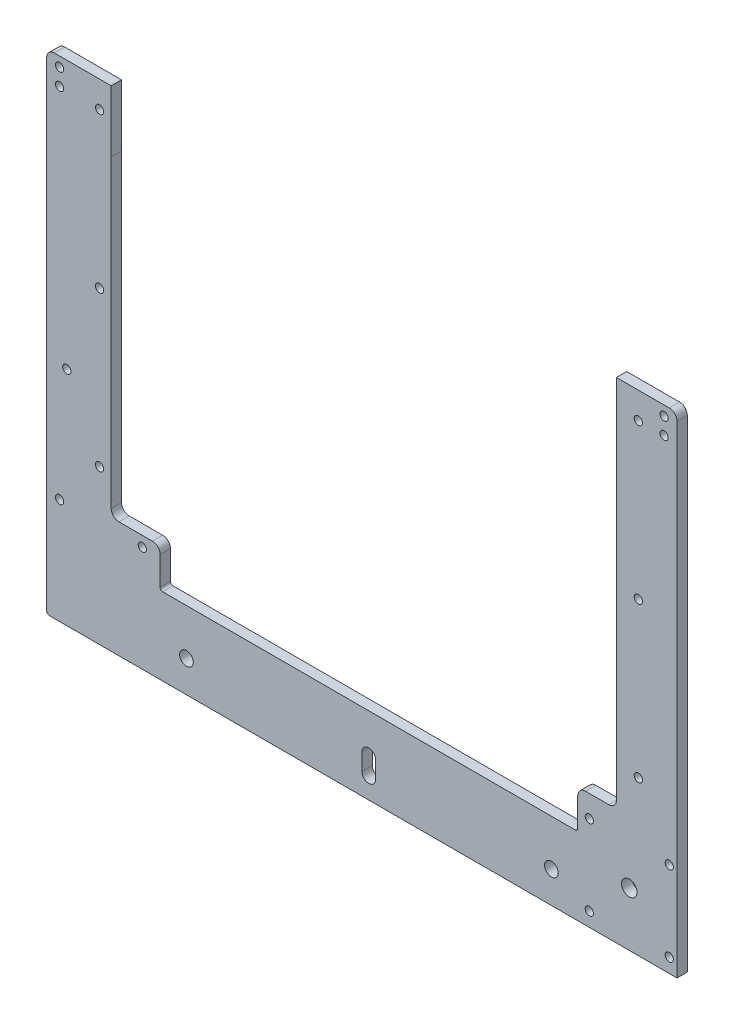
from build123d import *

# Parameters (mm, degrees)
RESSALTO_EXTRUS_O1_DEPTH = 4
FILETE1_R                = 3
M3_CLEARANCE_HOLE1_D     = 3.2
FURO_COM_FOLGA_DE_M32_D  = 2.87
M3_CLEARANCE_HOLE2_D     = 3.2
SKETCH3_W                = 27.430623534
SKETCH3_H                = 190
CUT_EXTRUDE1_DEPTH       = 10
BOSS_EXTRUDE1_DEPTH      = 4
FILLET3_R                = 3
BOSS_EXTRUDE3_DEPTH      = 4
M3_CLEARANCE_HOLE4_D     = 3.2
FILLET5_R                = 3
M5_CLEARANCE_HOLE1_D     = 5.3
SKETCH15_R               = 3
CUT_EXTRUDE6_DEPTH       = 5
SKETCH17_W               = 196
SKETCH17_H               = 23.942856981
CUT_EXTRUDE8_DEPTH       = 5
M3_CLEARANCE_HOLE6_D     = 3.2
M3_CLEARANCE_HOLE5_D     = 3.2
CUT_EXTRUDE9_DEPTH       = 4


with BuildPart() as part:
    # Esboço1 → Ressalto-extrusão1 (new body)
    with BuildSketch(Plane.XY):
        with BuildLine():
            Line((168.243612151, -138.115636704), (-79.756387849, -138.115636704))
            ThreePointArc((-79.756387849, -138.115636704), (-80.46349463, -137.822743485), (-80.756387849, -137.115636704))
            Line((-80.756387849, -137.115636704), (-80.756387849, 48.884363296))
            ThreePointArc((-80.756387849, 48.884363296), (-79.877708192, 51.005683639), (-77.756387849, 51.884363296))
            Line((-77.756387849, 51.884363296), (166.243612151, 51.884363296))
            ThreePointArc((166.243612151, 51.884363296), (168.364932495, 51.005683639), (169.243612151, 48.884363296))
            Line((169.243612151, 48.884363296), (169.243612151, -137.115636704))
            ThreePointArc((169.243612151, -137.115636704), (168.950718933, -137.822743485), (168.243612151, -138.115636704))
        make_face()
        with BuildLine():
            Line((-36.756387849, -93.115636704), (-55.756387849, -93.115636704))
            Line((-55.756387849, -93.115636704), (-55.756387849, -79.115636704))
            Line((-55.756387849, -79.115636704), (-55.756387849, 27.884363296))
            ThreePointArc((-55.756387849, 27.884363296), (-54.877708192, 30.005683639), (-52.756387849, 30.884363296))
            Line((-52.756387849, 30.884363296), (141.243612151, 30.884363296))
            ThreePointArc((141.243612151, 30.884363296), (143.364932495, 30.005683639), (144.243612151, 27.884363296))
            Line((144.243612151, 27.884363296), (144.243612151, -79.115636704))
            Line((144.243612151, -79.115636704), (144.243612151, -93.115636704))
            Line((144.243612151, -93.115636704), (125.243612151, -93.115636704))
            Line((125.243612151, -93.115636704), (125.243612151, -107.115636704))
            ThreePointArc((125.243612151, -107.115636704), (124.950718933, -107.822743485), (124.243612151, -108.115636704))
            Line((124.243612151, -108.115636704), (-35.756387849, -108.115636704))
            ThreePointArc((-35.756387849, -108.115636704), (-36.46349463, -107.822743485), (-36.756387849, -107.115636704))
            Line((-36.756387849, -107.115636704), (-36.756387849, -93.115636704))
        make_face(mode=Mode.SUBTRACT)
    extrude(amount=RESSALTO_EXTRUS_O1_DEPTH)

    # Filete1
    filete1_edges = [part.edges().sort_by_distance(p)[0] for p in [
        (-55.756387849, -93.115636704, 2),
        (-36.756387849, -93.115636704, 2),
        (125.243612151, -93.115636704, 2),
        (144.243612151, -93.115636704, 2),
    ]]
    fillet(filete1_edges, radius=FILETE1_R)

    # M3 Clearance Hole1 (through all)
    with Locations(Plane(origin=(0, 0, 0), x_dir=(-1, 0, 0), z_dir=(0, 0, -1))):
        with Locations((-164.230041881, -97.102981335), (43.669958119, -97.102981335), (75.742817578, -97.102981335)):
            Hole(M3_CLEARANCE_HOLE1_D / 2)

    # Furo com folga de M32 (through all)
    with Locations(Plane.XY.offset(4)):
        with Locations((44.243612151, 46.98714614)):
            Hole(FURO_COM_FOLGA_DE_M32_D / 2)

    # M3 Clearance Hole2 (through all)
    with Locations(Plane.XY.offset(4)):
        with Locations((161.560317261, 35.480164232), (161.560317261, 4.480164232)):
            Hole(M3_CLEARANCE_HOLE2_D / 2)

    # Sketch3 → Cut-Extrude1 (cut)
    with BuildSketch(Plane.XY.offset(4)):
        with Locations((169.958923918, -43.115636704)):
            Rectangle(SKETCH3_W, SKETCH3_H)
    extrude(amount=-CUT_EXTRUDE1_DEPTH, mode=Mode.SUBTRACT)

    # Sketch5 → Boss-Extrude1 (add)
    with BuildSketch(Plane(origin=(0, 0, 0), x_dir=(-1, 0, 0), z_dir=(0, 0, -1))):
        with BuildLine():
            Line((-145.240285588, -97.500155699), (-140.243612151, -97.500155699))
            Line((-140.243612151, -97.500155699), (-140.243612151, 27.941506315))
            ThreePointArc((-140.243612151, 27.941506315), (-139.345176524, 30.025791447), (-137.244156422, 30.884363296))
            Line((-137.244156422, 30.884363296), (-145.240285588, 30.884363296))
            Line((-145.240285588, 30.884363296), (-145.240285588, -97.500155699))
        make_face()
    extrude(amount=-BOSS_EXTRUDE1_DEPTH)

    # Fillet3
    fillet3_edges = [part.edges().sort_by_distance(p)[0] for p in [
        (156.243612151, 51.884363296, 2),
    ]]
    fillet(fillet3_edges, radius=FILLET3_R)

    # Sketch10 → Boss-Extrude3 (add)
    with BuildSketch(Plane(origin=(0, 0, 0), x_dir=(-1, 0, 0), z_dir=(0, 0, -1))):
        with BuildLine():
            Line((-156.243612151, -138.115636704), (-156.243612151, 48.884363296))
            ThreePointArc((-156.243612151, 48.884363296), (-155.364932495, 51.005683639), (-153.243612151, 51.884363296))
            Line((-153.243612151, 51.884363296), (-163.743612151, 51.884363296))
            Line((-163.743612151, 51.884363296), (-163.743612151, -138.115636704))
            Line((-163.743612151, -138.115636704), (-156.243612151, -138.115636704))
        make_face()
    extrude(amount=-BOSS_EXTRUDE3_DEPTH)

    # M3 Clearance Hole4 (through all)
    with Locations(Plane(origin=(0, 0, 0), x_dir=(-1, 0, 0), z_dir=(0, 0, -1))):
        with Locations((-160.743612151, -101.615636704), (-160.743612151, -132.615636704), (-129.743612151, -132.615636704), (-129.743612151, -101.615636704)):
            Hole(M3_CLEARANCE_HOLE4_D / 2)

    # Fillet5
    fillet5_edges = [part.edges().sort_by_distance(p)[0] for p in [
        (140.243612151, -93.115636704, 2),
        (163.743612151, 51.884363296, 2),
    ]]
    fillet(fillet5_edges, radius=FILLET5_R)

    # M5 Clearance Hole1 (through all)
    with Locations(Plane(origin=(0, 0, 0), x_dir=(-1, 0, 0), z_dir=(0, 0, -1))):
        with Locations((-115.03361215, -125.8856367), (26.54638785, -125.8856367), (-44.189907873, -129.865636704)):
            Hole(M5_CLEARANCE_HOLE1_D / 2)

    # Sketch15 → Cut-Extrude6 (cut, through all)
    with BuildSketch(Plane(origin=(0, 0, 0), x_dir=(-1, 0, 0), z_dir=(0, 0, -1))):
        with Locations((-145.243612151, -117.115636704)):
            Circle(SKETCH15_R)
    extrude(amount=-CUT_EXTRUDE6_DEPTH, mode=Mode.SUBTRACT)

    # Sketch17 → Cut-Extrude8 (cut)
    with BuildSketch(Plane(origin=(0, 0, 0), x_dir=(-1, 0, 0), z_dir=(0, 0, -1))):
        with Locations((-42.243612151, 39.912934806)):
            Rectangle(SKETCH17_W, SKETCH17_H)
    extrude(amount=-CUT_EXTRUDE8_DEPTH, mode=Mode.SUBTRACT)

    # M3 Clearance Hole6 (through all)
    with Locations(Plane(origin=(0, 0, 0), x_dir=(-1, 0, 0), z_dir=(0, 0, -1))):
        with Locations((-148.743612151, -78.347886704), (-148.743612151, -18.347886704), (-148.743612151, 41.652113296), (60.256387849, 41.652113296), (60.256387849, -18.347886704), (60.256387849, -78.347886704), (72.959751747, -51.945636704)):
            Hole(M3_CLEARANCE_HOLE6_D / 2)

    # M3 Clearance Hole5 (through all)
    with Locations(Plane.XY.offset(4)):
        with Locations((-75.756387849, 41.652113296), (-75.756387849, 48.152113296), (158.743612151, 48.152113296), (158.743612151, 41.652113296)):
            Hole(M3_CLEARANCE_HOLE5_D / 2)

    # Sketch22 → Cut-Extrude9 (cut)
    with BuildSketch(Plane(origin=(0, 0, 0), x_dir=(-1, 0, 0), z_dir=(0, 0, -1))):
        with BuildLine():
            Line((-46.840844325, -129.865636704), (-46.840844325, -123.2156367))
            ThreePointArc((-46.840844325, -123.2156367), (-44.189907873, -120.564700249), (-41.538971422, -123.2156367))
            Line((-41.538971422, -123.2156367), (-41.538971422, -129.865636704))
            ThreePointArc((-41.538971422, -129.865636704), (-44.189907873, -132.516573155), (-46.840844325, -129.865636704))
        make_face()
    extrude(amount=-CUT_EXTRUDE9_DEPTH, mode=Mode.SUBTRACT)


solid = part.part
